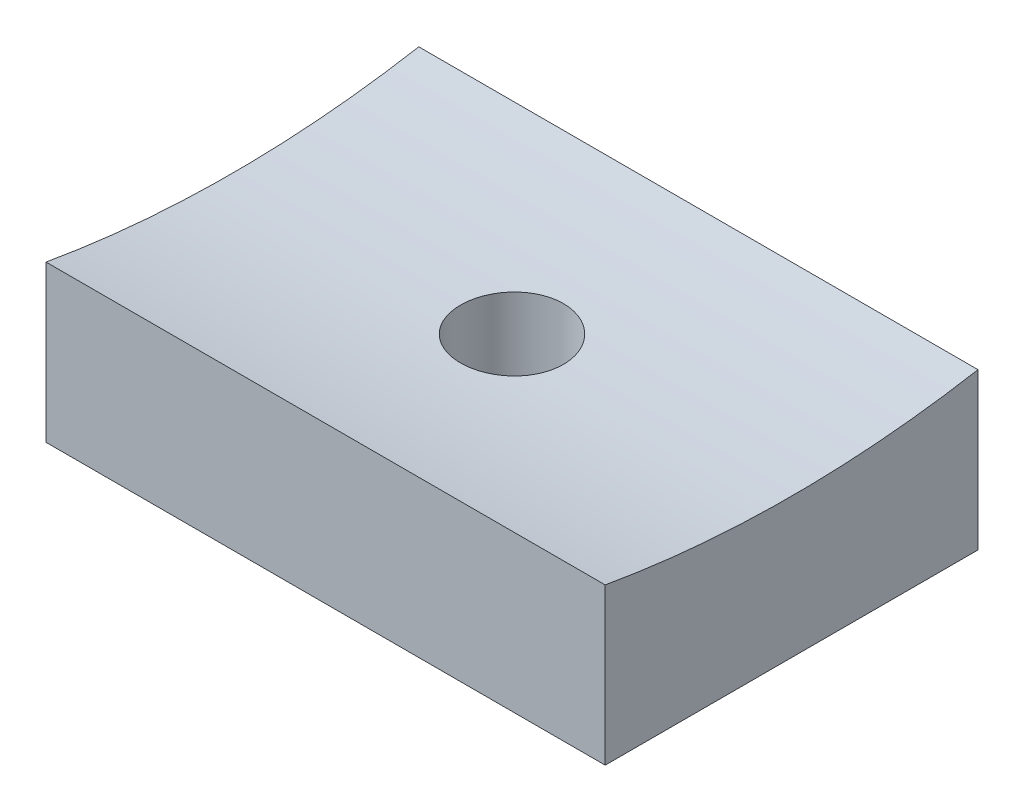
from build123d import *

# Parameters (mm, degrees)
SKETCH1_W                       = 19.05
SKETCH1_H                       = 12.7
EXTRUDE1_DEPTH                  = 41.275
SKETCH2_R                       = 36.5125
CUT_EXTRUDE1_DEPTH              = 41.275
F_6_32_TAPPED_HOLE1_D           = 2.7051
F_6_32_TAPPED_HOLE1_DEPTH       = 9.398
F_6_32_TAPPED_HOLE1_CBORE_D     = 3.5052
F_6_32_TAPPED_HOLE1_CBORE_DEPTH = 7.112
F_6_32_TAPPED_HOLE1_TIP         = 0.81269403


with BuildPart() as part:
    # Sketch1 → Extrude1 (new body)
    with BuildSketch(Plane(origin=(0, 0, 0), x_dir=(1, 0, 0), z_dir=(0, 1, 0))):
        Rectangle(SKETCH1_W, SKETCH1_H)
    extrude(amount=EXTRUDE1_DEPTH)

    # Sketch2 → Cut-Extrude1 (cut)
    with BuildSketch(Plane.ZY.offset(9.525)):
        with Locations((0, 41.275)):
            Circle(SKETCH2_R)
    extrude(amount=-CUT_EXTRUDE1_DEPTH, mode=Mode.SUBTRACT)

    # #6-32 Tapped Hole1
    with Locations(Plane(origin=(0, 0, 0), x_dir=(0, 0, -1), z_dir=(0, -1, 0))):
        with Locations((0, 0)):
            CounterBoreHole(F_6_32_TAPPED_HOLE1_D / 2, F_6_32_TAPPED_HOLE1_CBORE_D / 2, F_6_32_TAPPED_HOLE1_CBORE_DEPTH, depth=F_6_32_TAPPED_HOLE1_DEPTH)
            with Locations((0, 0, -(F_6_32_TAPPED_HOLE1_DEPTH + F_6_32_TAPPED_HOLE1_TIP / 2))):  # 118° drill point
                Cone(0, F_6_32_TAPPED_HOLE1_D / 2, F_6_32_TAPPED_HOLE1_TIP, mode=Mode.SUBTRACT)


solid = part.part
